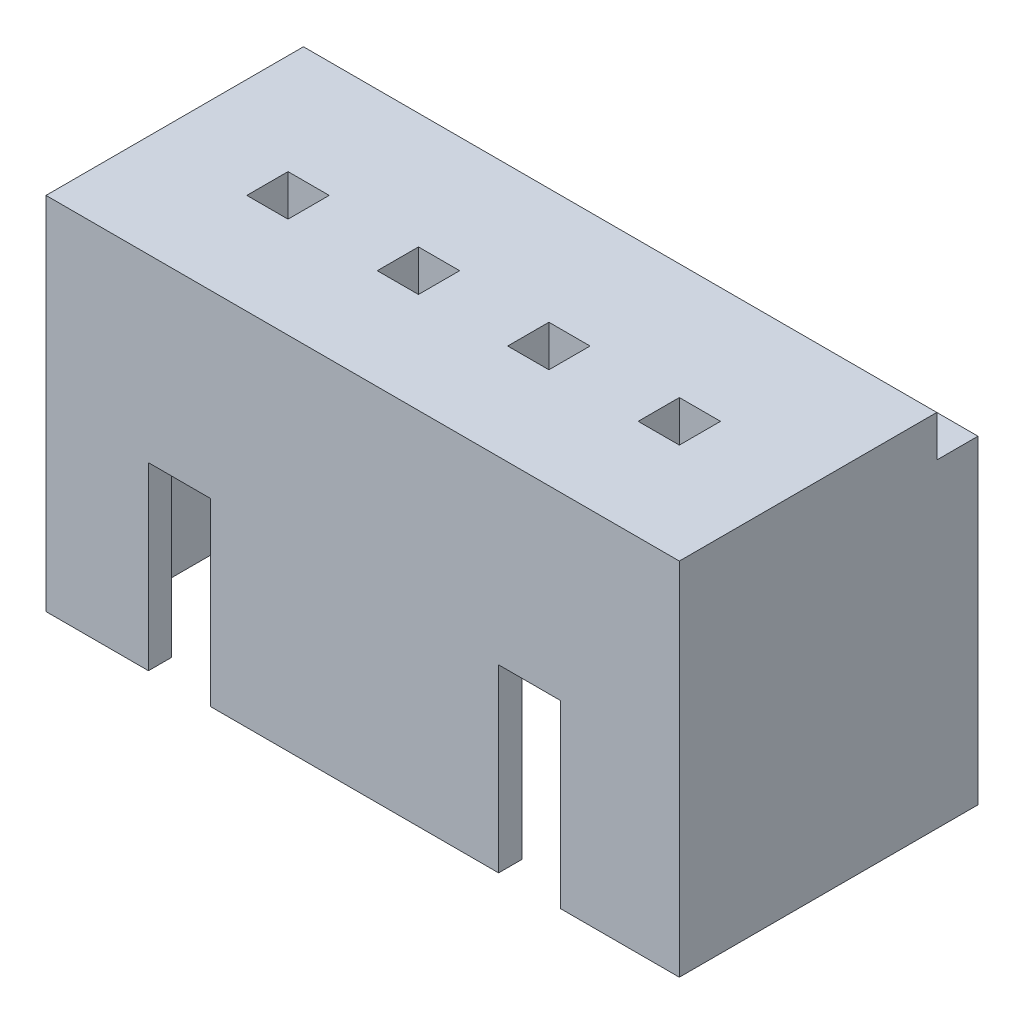
from build123d import *

# Parameters (mm, degrees)
SKETCH1_W           = 12.3
SKETCH1_H           = 5.8
BOSS_EXTRUDE1_DEPTH = 7
SKETCH3_W           = 11
SKETCH3_H           = 4.9
CUT_EXTRUDE1_DEPTH  = 5
SKETCH4_W           = 1.2
SKETCH4_H           = 3.5
CUT_EXTRUDE2_DEPTH  = 4
SKETCH5_W           = 12.3
SKETCH5_H           = 0.8
CUT_EXTRUDE3_DEPTH  = 0.8
SKETCH6_W           = 0.8
SKETCH6_H           = 0.8
CUT_EXTRUDE4_DEPTH  = 10
SKETCH7_W           = 11
SKETCH7_H           = 1
CUT_EXTRUDE5_DEPTH  = 0.3


with BuildPart() as part:
    # Sketch1 → Boss-Extrude1 (new body)
    with BuildSketch(Plane(origin=(0, 0, 0), x_dir=(1, 0, 0), z_dir=(0, 1, 0))):
        Rectangle(SKETCH1_W, SKETCH1_H)
    extrude(amount=BOSS_EXTRUDE1_DEPTH)

    # Sketch3 → Cut-Extrude1 (cut)
    with BuildSketch(Plane.XZ):
        Rectangle(SKETCH3_W, SKETCH3_H)
    extrude(amount=-CUT_EXTRUDE1_DEPTH, mode=Mode.SUBTRACT)

    # Sketch4 → Cut-Extrude2 (cut)
    with BuildSketch(Plane.XY.offset(2.9)):
        with Locations((-3.56, 1.75)):
            Rectangle(SKETCH4_W, SKETCH4_H)
        with Locations((3.24, 1.75)):
            Rectangle(SKETCH4_W, SKETCH4_H)
    extrude(amount=-CUT_EXTRUDE2_DEPTH, mode=Mode.SUBTRACT)

    # Sketch5 → Cut-Extrude3 (cut)
    with BuildSketch(Plane(origin=(0, 7, 0), x_dir=(1, 0, 0), z_dir=(0, 1, 0))):
        with Locations((0, 2.5)):
            Rectangle(SKETCH5_W, SKETCH5_H)
    extrude(amount=-CUT_EXTRUDE3_DEPTH, mode=Mode.SUBTRACT)

    # Sketch6 → Cut-Extrude4 (cut)
    with BuildSketch(Plane(origin=(0, 7, 0), x_dir=(1, 0, 0), z_dir=(0, 1, 0))):
        with Locations((3.8, -0.55)):
            Rectangle(SKETCH6_W, SKETCH6_H)
        with Locations((-1.266666667, -0.55)):
            Rectangle(SKETCH6_W, SKETCH6_H)
        with Locations((1.266666667, -0.55)):
            Rectangle(SKETCH6_W, SKETCH6_H)
        with Locations((-3.8, -0.55)):
            Rectangle(SKETCH6_W, SKETCH6_H)
    extrude(amount=-CUT_EXTRUDE4_DEPTH, mode=Mode.SUBTRACT)

    # Sketch7 → Cut-Extrude5 (cut)
    with BuildSketch(Plane.XZ.offset(-5)):
        with Locations((0, -1.95)):
            Rectangle(SKETCH7_W, SKETCH7_H)
    extrude(amount=-CUT_EXTRUDE5_DEPTH, mode=Mode.SUBTRACT)


solid = part.part
